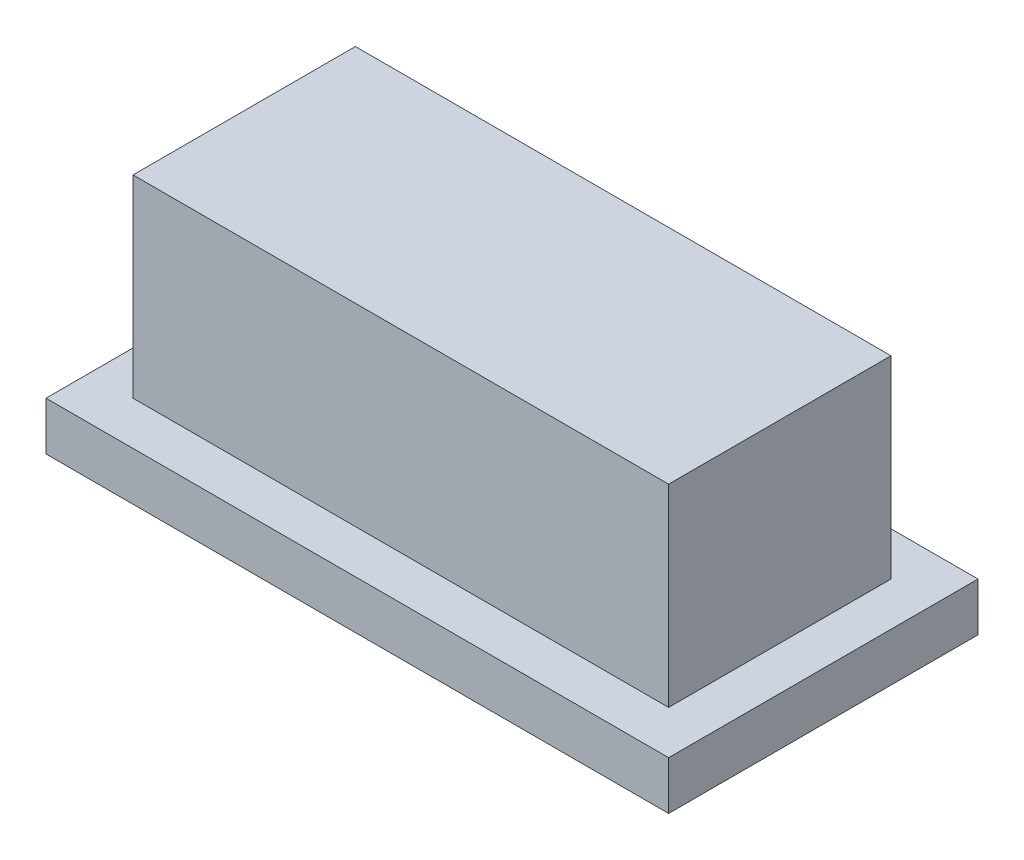
from build123d import *

# Parameters (mm, degrees)
SKETCH1_W           = 12.88
SKETCH1_H           = 6.4
BOSS_EXTRUDE1_DEPTH = 1
SKETCH3_W           = 11.08
SKETCH3_H           = 4.6
BOSS_EXTRUDE2_DEPTH = 4
SKETCH4_W           = 3.2
SKETCH4_H           = 2.2
CUT_EXTRUDE1_DEPTH  = 3.1


with BuildPart() as part:
    # Sketch1 → Boss-Extrude1 (new body)
    with BuildSketch(Plane(origin=(0, 0, 0), x_dir=(1, 0, 0), z_dir=(0, 1, 0))):
        with Locations((6.44, 3.2)):
            Rectangle(SKETCH1_W, SKETCH1_H)
    extrude(amount=BOSS_EXTRUDE1_DEPTH)

    # Sketch3 → Boss-Extrude2 (add)
    with BuildSketch(Plane(origin=(0, 1, 0), x_dir=(1, 0, 0), z_dir=(0, 1, 0))):
        with Locations((6.44, 3.2)):
            Rectangle(SKETCH3_W, SKETCH3_H)
    extrude(amount=BOSS_EXTRUDE2_DEPTH)

    # Sketch4 → Cut-Extrude1 (cut)
    with BuildSketch(Plane.XZ):
        with Locations((6.44, -3.2)):
            Rectangle(SKETCH4_W, SKETCH4_H)
    extrude(amount=-CUT_EXTRUDE1_DEPTH, mode=Mode.SUBTRACT)


solid = part.part
